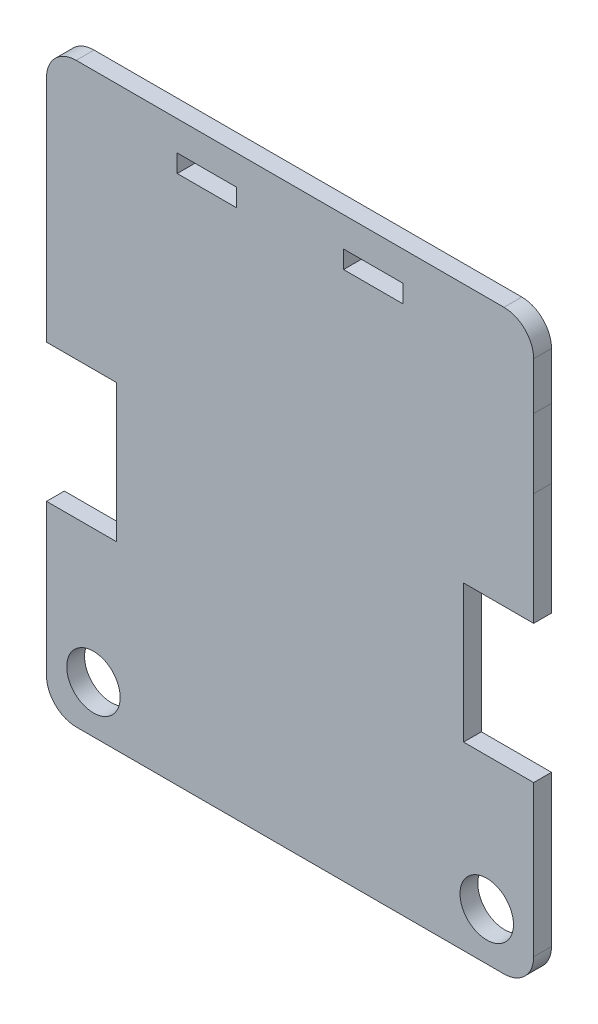
from build123d import *

# Parameters (mm, degrees)
MODEL_R                 = 4.5
MODEL_W                 = 10
MODEL_H                 = 3
SALIENTE_EXTRUIR1_DEPTH = 3


with BuildPart() as part:
    # Model → Saliente-Extruir1 (new body)
    with BuildSketch(Plane.XY):
        with BuildLine():
            Line((17.831945339, 53.688342713), (41.944056128, 53.688342713))
            Line((41.944056128, 53.688342713), (62.686495879, 53.688342713))
            Line((62.686495879, 53.688342713), (72.203528383, 53.688342713))
            ThreePointArc((72.203528383, 53.688342713), (75.739062289, 52.223876619), (77.203528383, 48.688342713))
            Line((77.203528383, 48.688342713), (77.200462039, 40.688342713))
            Line((77.200462039, 40.688342713), (77.203528383, 29.009907229))
            Line((77.203528383, 29.009907229), (77.203528383, 19.550667198))
            Line((77.203528383, 19.550667198), (77.203528383, 10.10455356))
            Line((77.203528383, 10.10455356), (65.403528383, 10.10455356))
            Line((65.403528383, 10.10455356), (65.403528383, -13.09544644))
            Line((65.403528383, -13.09544644), (77.203528383, -13.09544644))
            Line((77.203528383, -13.09544644), (77.203528383, -33.19043659))
            Line((77.203528383, -33.19043659), (77.203528383, -38.49544644))
            ThreePointArc((77.203528383, -38.49544644), (75.739062152, -42.030980095), (72.203528383, -43.495446053))
            Line((72.203528383, -43.495446053), (0.206594728, -43.495446053))
            ThreePointArc((0.206594728, -43.495446053), (-3.328939178, -42.030979958), (-4.793405272, -38.495446053))
            Line((-4.793405272, -38.495446053), (-4.793405272, -13.09544644))
            Line((-4.793405272, -13.09544644), (7.006594728, -13.09544644))
            Line((7.006594728, -13.09544644), (7.006594728, 10.10455356))
            Line((7.006594728, 10.10455356), (-4.793405272, 10.10455356))
            Line((-4.793405272, 10.10455356), (-4.793405272, 40.688342713))
            Line((-4.793405272, 40.688342713), (-4.793405272, 48.688342713))
            ThreePointArc((-4.793405272, 48.688342713), (-3.328939178, 52.223876619), (0.206594728, 53.688342713))
            Line((0.206594728, 53.688342713), (6.681518597, 53.688342713))
            Line((6.681518597, 53.688342713), (17.831945339, 53.688342713))
        make_face()
        with Locations((69.303528383, -35.49544644)):
            Circle(MODEL_R, mode=Mode.SUBTRACT)
        with Locations((3.103528383, -35.49544644)):
            Circle(MODEL_R, mode=Mode.SUBTRACT)
        with Locations((22.203528383, 47.188342713)):
            Rectangle(MODEL_W, MODEL_H, mode=Mode.SUBTRACT)
        with Locations((50.203528383, 47.188342713)):
            Rectangle(MODEL_W, MODEL_H, mode=Mode.SUBTRACT)
    extrude(amount=SALIENTE_EXTRUIR1_DEPTH)


solid = part.part
